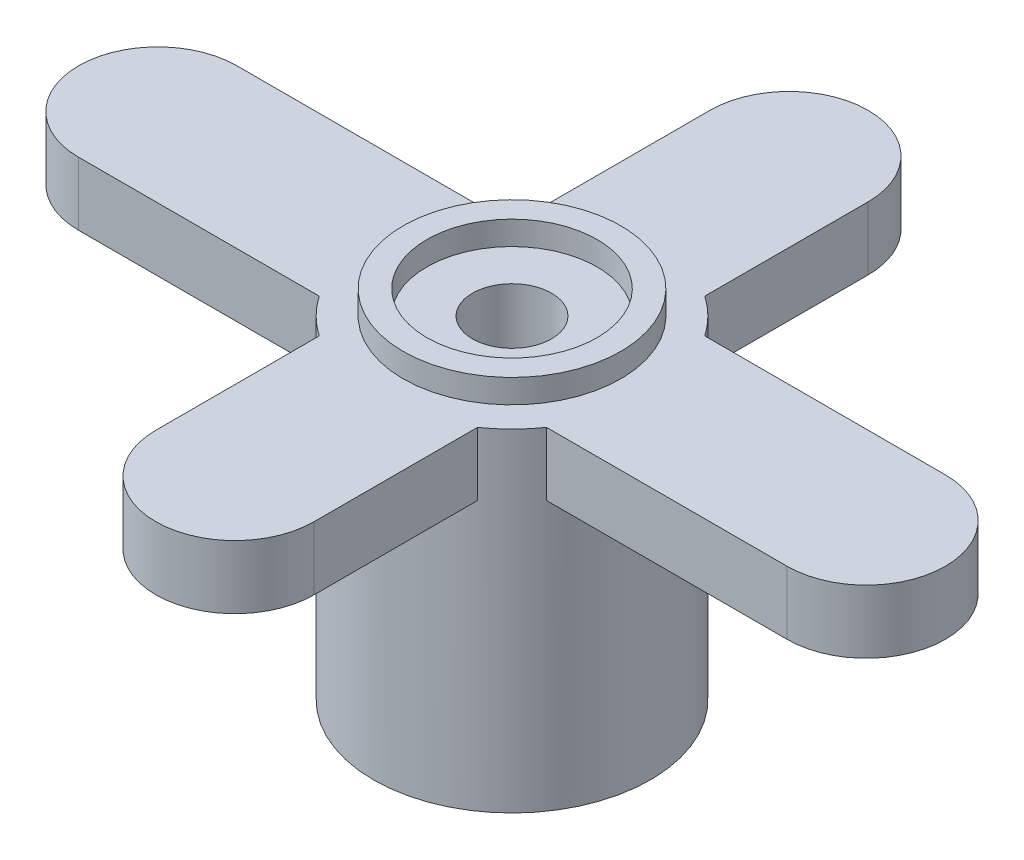
from build123d import *

# Parameters (mm, degrees)
SZKIC1_R                    = 3.5
DODANIE_WYCI_GNI_CIE1_DEPTH = 9
SZKIC2_R                    = 1.9
WYTNIJ_WYCI_GNI_CIE1_DEPTH  = 3.5
SZKIC3_R                    = 2
DODANIE_WYCI_GNI_CIE2_DEPTH = 1.6
WYTNIJ_WYCI_GNI_CIE2_START  = -0.6
SZKIC4_R                    = 2.15
WYTNIJ_WYCI_GNI_CIE2_DEPTH  = 0.6
SZKIC5_R                    = 1
WYTNIJ_WYCI_GNI_CIE3_DEPTH  = 31.6
SZKIC6_R                    = 3.5
SZKIC6_R_2                  = 2.75
WYTNIJ_WYCI_GNI_CIE4_DEPTH  = 0.6


with BuildPart() as part:
    # Szkic1 → Dodanie-wyciągnięcie1 (new body)
    with BuildSketch(Plane(origin=(0, 0, 0), x_dir=(1, 0, 0), z_dir=(0, 1, 0))):
        Circle(SZKIC1_R)
    extrude(amount=DODANIE_WYCI_GNI_CIE1_DEPTH)

    # Szkic2 → Wytnij-wyciągnięcie1 (cut)
    with BuildSketch(Plane.XZ):
        Circle(SZKIC2_R)
    extrude(amount=-WYTNIJ_WYCI_GNI_CIE1_DEPTH, mode=Mode.SUBTRACT)

    # Szkic3 → Dodanie-wyciągnięcie2 (add)
    with BuildSketch(Plane(origin=(0, 8.4, 0), x_dir=(1, 0, 0), z_dir=(0, 1, 0))):
        with Locations((-8.95, 0)):
            Circle(SZKIC3_R)
        with BuildLine():
            Line((-2, 2), (-8.95, 2))
            ThreePointArc((-8.95, 2), (-7.535786438, 1.414213562), (-6.95, 0))
            ThreePointArc((-6.95, 0), (-7.535786438, -1.414213562), (-8.95, -2))
            Line((-8.95, -2), (-2, -2))
            Line((-2, -2), (-2, 2))
        make_face()
        with Locations((0, 7)):
            Circle(SZKIC3_R)
        with BuildLine():
            Line((-2, 7), (-2, 2))
            Line((-2, 2), (0, 2))
            Line((0, 2), (2, 2))
            Line((2, 2), (2, 7))
            ThreePointArc((2, 7), (0, 5), (-2, 7))
        make_face()
        with BuildLine():
            Line((8.95, 2), (2, 2))
            Line((2, 2), (2, 0))
            Line((2, 0), (2, -2))
            Line((2, -2), (8.95, -2))
            ThreePointArc((8.95, -2), (6.95, 0), (8.95, 2))
        make_face()
        with Locations((8.95, 0)):
            Circle(SZKIC3_R)
        with Locations((0, -7)):
            Circle(SZKIC3_R)
        with BuildLine():
            Line((2, -2), (-2, -2))
            Line((-2, -2), (-2, -7))
            ThreePointArc((-2, -7), (0, -5), (2, -7))
            Line((2, -7), (2, -2))
        make_face()
    extrude(amount=-DODANIE_WYCI_GNI_CIE2_DEPTH)

    # Szkic4 → Wytnij-wyciągnięcie2 (cut)
    with BuildSketch(Plane(origin=(0, 9, 0), x_dir=(1, 0, 0), z_dir=(0, 1, 0)).offset(WYTNIJ_WYCI_GNI_CIE2_START)):
        Circle(SZKIC4_R)
    extrude(amount=WYTNIJ_WYCI_GNI_CIE2_DEPTH, mode=Mode.SUBTRACT)

    # Szkic5 → Wytnij-wyciągnięcie3 (cut)
    with BuildSketch(Plane(origin=(0, 8.4, 0), x_dir=(1, 0, 0), z_dir=(0, 1, 0))):
        Circle(SZKIC5_R)
    extrude(amount=-WYTNIJ_WYCI_GNI_CIE3_DEPTH, mode=Mode.SUBTRACT)

    # Szkic6 → Wytnij-wyciągnięcie4 (cut)
    with BuildSketch(Plane(origin=(0, 9, 0), x_dir=(1, 0, 0), z_dir=(0, 1, 0))):
        Circle(SZKIC6_R)
        Circle(SZKIC6_R_2, mode=Mode.SUBTRACT)
    extrude(amount=-WYTNIJ_WYCI_GNI_CIE4_DEPTH, mode=Mode.SUBTRACT)


solid = part.part
